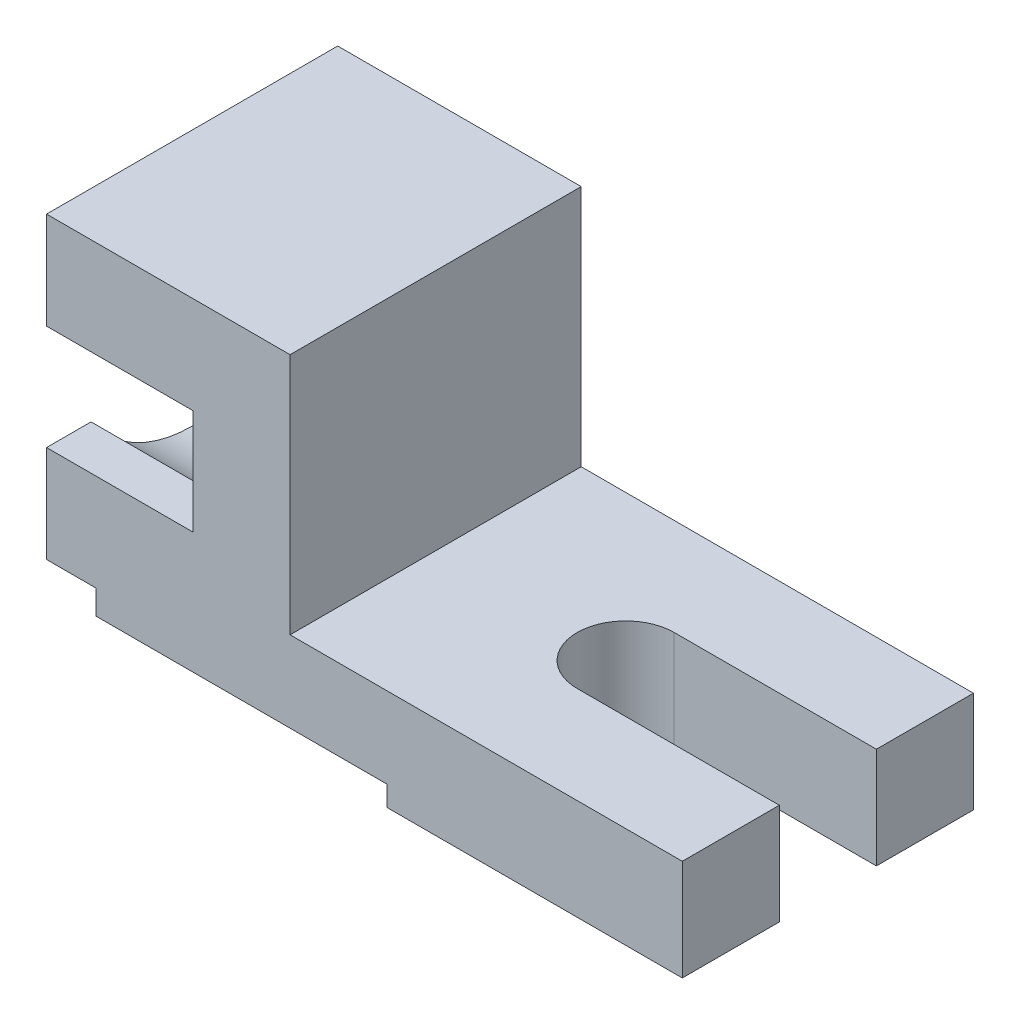
from build123d import *

# Parameters (mm, degrees)
BOSS_EXTRUDE7_DEPTH      = 72
CUT_EXTRUDE4_DEPTH       = 72
BOSS_EXTRUDE8_DEPTH      = 36
CUT_EXTRUDE10_DEPTH      = 30
SKETCH17_R               = 12
CUT_EXTRUDE11_DEPTH      = 30
CUT_EXTRUDE11_DEPTH_BACK = 1


with BuildPart() as part:
    # Sketch7 → Boss-Extrude7 (new body)
    with BuildSketch(Plane.XY):
        Polygon((-85.777777778, 17.777777778), (-13.777777778, 17.777777778), (-13.777777778, 12.777777778), (59.222222222, 12.777777778), (59.222222222, 37.777777778), (-13.777777778, 37.777777778), (-37.777777778, 37.777777778), (-37.777777778, 97.777777778), (-73.777777778, 97.777777778), (-73.777777778, 73.777777778), (-61.777777778, 73.777777778), (-61.777777778, 47.777777778), (-73.777777778, 47.777777778), (-85.777777778, 47.777777778), align=None)
    extrude(amount=-BOSS_EXTRUDE7_DEPTH)

    # Sketch9 → Cut-Extrude4 (cut)
    with BuildSketch(Plane(origin=(0, 37.777777778, 0), x_dir=(1, 0, 0), z_dir=(0, 1, 0))):
        with BuildLine():
            Line((59.222222222, 24), (9.222222222, 24))
            ThreePointArc((9.222222222, 24), (-2.777777778, 36), (9.222222222, 48))
            Line((9.222222222, 48), (59.222222222, 48))
            Line((59.222222222, 48), (59.222222222, 24))
        make_face()
    extrude(amount=-CUT_EXTRUDE4_DEPTH, mode=Mode.SUBTRACT)

    # Sketch12 → Boss-Extrude8 (add)
    with BuildSketch(Plane.ZY.offset(62)):
        with BuildLine():
            ThreePointArc((-61, 47.777777778), (-36, 34.36090173), (-11, 47.777777778))
            Line((-11, 47.777777778), (0, 47.777777778))
            Line((0, 47.777777778), (0, 23.789694875))
            Line((0, 23.789694875), (-50, 23.789694875))
            Line((-50, 23.789694875), (-50, 17.777777778))
            Line((-50, 17.777777778), (-72, 17.777777778))
            Line((-72, 17.777777778), (-72, 47.777777778))
            Line((-72, 47.777777778), (-61, 47.777777778))
        make_face()
        with BuildLine():
            Line((-72, 73.777777778), (-61, 73.777777778))
            ThreePointArc((-61, 73.777777778), (-36, 87.194653826), (-11, 73.777777778))
            Line((-11, 73.777777778), (0, 73.777777778))
            Line((0, 73.777777778), (0, 97.777777778))
            Line((0, 97.777777778), (-72, 97.777777778))
            Line((-72, 97.777777778), (-72, 73.777777778))
        make_face()
    extrude(amount=BOSS_EXTRUDE8_DEPTH)

    # Sketch13 → Cut-Extrude10 (cut)
    with BuildSketch(Plane.ZY.offset(62)):
        with BuildLine():
            ThreePointArc((-11, 47.777777778), (-36, 34.36090173), (-61, 47.777777778))
            Line((-61, 47.777777778), (-11, 47.777777778))
        make_face()
        with BuildLine():
            ThreePointArc((-61, 73.777777778), (-36, 87.194653826), (-11, 73.777777778))
            Line((-11, 73.777777778), (-28.562094012, 73.777777778))
            Line((-28.562094012, 73.777777778), (-43.437905988, 73.777777778))
            Line((-43.437905988, 73.777777778), (-61, 73.777777778))
        make_face()
    extrude(amount=CUT_EXTRUDE10_DEPTH, mode=Mode.SUBTRACT)

    # Sketch17 → Cut-Extrude11 (cut, two sides)
    with BuildSketch(Plane.ZY.offset(61.777777778)) as cut_extrude11_sk:
        with Locations((-35.93265931, 64.574548991)):
            Circle(SKETCH17_R)
    extrude(amount=CUT_EXTRUDE11_DEPTH, mode=Mode.SUBTRACT)
    extrude(cut_extrude11_sk.sketch, amount=-CUT_EXTRUDE11_DEPTH_BACK, mode=Mode.SUBTRACT)


solid = part.part
